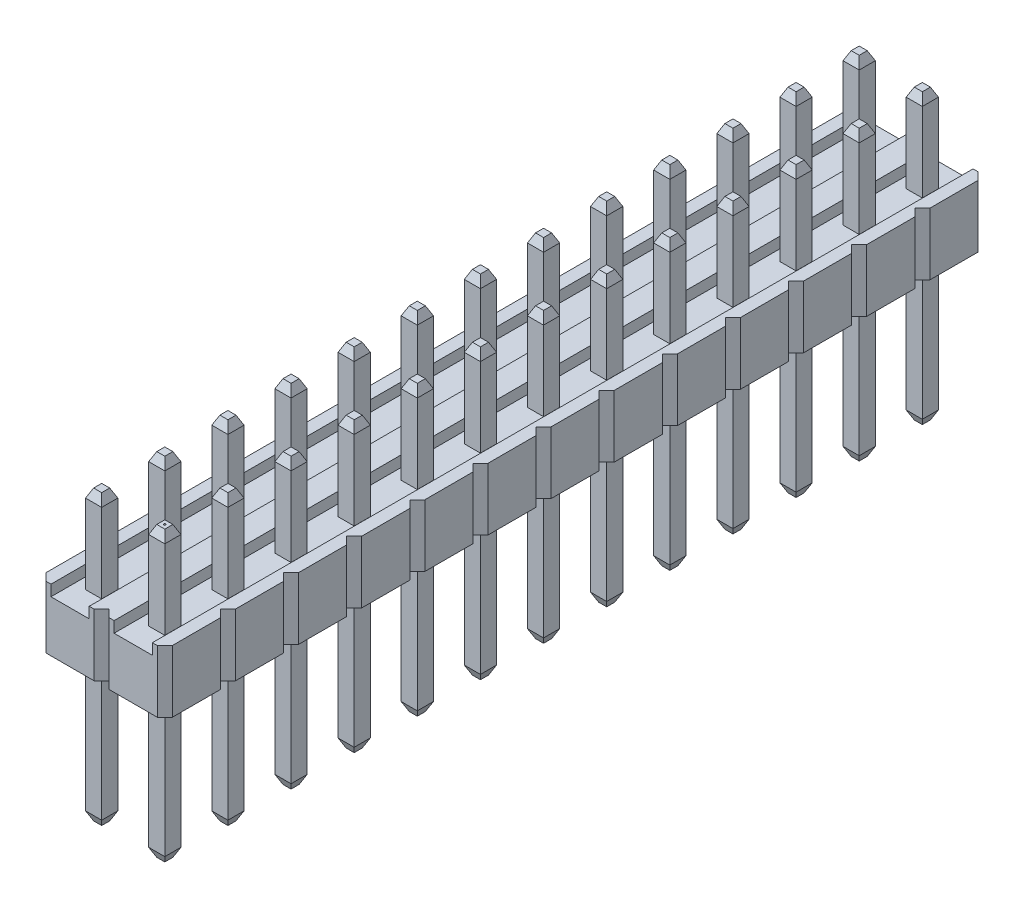
from build123d import *

# Parameters (mm, degrees)
EXTRUDE1_DEPTH                     = 2.5
SKETCH2_W                          = 1.54
SKETCH2_H                          = 0.508742985
CUT_EXTRUDE1_DEPTH                 = 12.5
SKETCH3_W                          = 0.65
SKETCH3_H                          = 0.65
EXTRUDE2_DEPTH                     = 3.54
CHAMFER1_SIZE                      = 0.35
CHAMFER1_SIZE2                     = 0.16320768
CHAMFER1_PART_2_SIZE               = 0.35
CHAMFER1_PART_2_SIZE2              = 0.16320768
CHAMFER1_PART_3_SIZE               = 0.35
CHAMFER1_PART_3_SIZE2              = 0.16320768
CHAMFER1_PART_4_SIZE               = 0.35
CHAMFER1_PART_4_SIZE2              = 0.16320768
SKETCH4_W                          = 0.65
SKETCH4_H                          = 0.65
EXTRUDE3_DEPTH                     = 6
CHAMFER2_SIZE                      = 0.35
CHAMFER2_SIZE2                     = 0.16320768
CHAMFER2_PART_2_SIZE               = 0.35
CHAMFER2_PART_2_SIZE2              = 0.16320768
CHAMFER2_PART_3_SIZE               = 0.35
CHAMFER2_PART_3_SIZE2              = 0.16320768
CHAMFER2_PART_4_SIZE               = 0.35
CHAMFER2_PART_4_SIZE2              = 0.16320768
LPATTERN3_COUNT                    = 13
LPATTERN3_PITCH                    = 2.54
LPATTERN3_COUNT_DIR2               = 2
LPATTERN3_PITCH_DIR2               = 2.54
LPATTERN4_COUNT                    = 13
LPATTERN4_PITCH                    = 2.54
LPATTERN4_COUNT_DIR2               = 2
LPATTERN4_PITCH_DIR2               = 2.54
CHAMFER1_OF_LPATTERN4_SIZE2        = 0.16320768
CHAMFER1_OF_LPATTERN4_SIZE         = 0.35
CHAMFER1_PART_2_OF_LPATTERN4_SIZE2 = 0.16320768
CHAMFER1_PART_2_OF_LPATTERN4_SIZE  = 0.35
CHAMFER1_PART_3_OF_LPATTERN4_SIZE2 = 0.16320768
CHAMFER1_PART_3_OF_LPATTERN4_SIZE  = 0.35
CHAMFER1_PART_4_OF_LPATTERN4_SIZE2 = 0.16320768
CHAMFER1_PART_4_OF_LPATTERN4_SIZE  = 0.35
CHAMFER2_OF_LPATTERN4_SIZE2        = 0.16320768
CHAMFER2_OF_LPATTERN4_SIZE         = 0.35
CHAMFER2_PART_2_OF_LPATTERN4_SIZE2 = 0.16320768
CHAMFER2_PART_2_OF_LPATTERN4_SIZE  = 0.35
CHAMFER2_PART_3_OF_LPATTERN4_SIZE2 = 0.16320768
CHAMFER2_PART_3_OF_LPATTERN4_SIZE  = 0.35
CHAMFER2_PART_4_OF_LPATTERN4_SIZE2 = 0.16320768
CHAMFER2_PART_4_OF_LPATTERN4_SIZE  = 0.35
ESBO_O1_R                          = 0.039608668
CORTE_EXTRUS_O1_DEPTH              = 0.1


with BuildPart() as part:
    # Sketch1 → Extrude1 (new body)
    with BuildSketch(Plane(origin=(0, 0, 0), x_dir=(1, 0, 0), z_dir=(0, 1, 0))):
        Polygon((-0.97, 1.27), (0.97, 1.27), (1.27, 0.97), (1.27, -0.97), (0.97, -1.27), (-0.97, -1.27), (-1.27, -0.97), (-1.27, 0.97), align=None)
    extrude1 = extrude(amount=EXTRUDE1_DEPTH)

    # Sketch2 → Cut-Extrude1 (cut)
    with BuildSketch(Plane.XY.offset(1.27)):
        with Locations((0, 2.314371493)):
            Rectangle(SKETCH2_W, SKETCH2_H)
    cut_extrude1 = extrude(amount=-CUT_EXTRUDE1_DEPTH, mode=Mode.SUBTRACT)

    # Sketch3 → Extrude2 (add)
    with BuildSketch(Plane(origin=(0, 2.06, 0), x_dir=(-1, 0, 0), z_dir=(0, 1, 0))):
        Rectangle(SKETCH3_W, SKETCH3_H)
    extrude2 = extrude(amount=EXTRUDE2_DEPTH)

    # Chamfer1
    chamfer1_edges = [part.edges().sort_by_distance(p)[0] for p in [
        (-0.325, 5.6, 0),
    ]]
    chamfer1_side = [part.faces().sort_by_distance(p)[0] for p in [
        (-0.325, 3.83, 0),
    ]]
    chamfer(chamfer1_edges, length=CHAMFER1_SIZE, length2=CHAMFER1_SIZE2, reference=chamfer1_side[0])

    # Chamfer1 part 2
    chamfer1_part_2_edges = [part.edges().sort_by_distance(p)[0] for p in [
        (0, 5.6, 0.325),
    ]]
    chamfer1_part_2_side = [part.faces().sort_by_distance(p)[0] for p in [
        (0, 3.83, 0.325),
    ]]
    chamfer(chamfer1_part_2_edges, length=CHAMFER1_PART_2_SIZE, length2=CHAMFER1_PART_2_SIZE2, reference=chamfer1_part_2_side[0])

    # Chamfer1 part 3
    chamfer1_part_3_edges = [part.edges().sort_by_distance(p)[0] for p in [
        (0.325, 5.6, 0),
    ]]
    chamfer1_part_3_side = [part.faces().sort_by_distance(p)[0] for p in [
        (0.325, 3.83, 0),
    ]]
    chamfer(chamfer1_part_3_edges, length=CHAMFER1_PART_3_SIZE, length2=CHAMFER1_PART_3_SIZE2, reference=chamfer1_part_3_side[0])

    # Chamfer1 part 4
    chamfer1_part_4_edges = [part.edges().sort_by_distance(p)[0] for p in [
        (0, 5.6, -0.325),
    ]]
    chamfer1_part_4_side = [part.faces().sort_by_distance(p)[0] for p in [
        (0, 3.83, -0.325),
    ]]
    chamfer(chamfer1_part_4_edges, length=CHAMFER1_PART_4_SIZE, length2=CHAMFER1_PART_4_SIZE2, reference=chamfer1_part_4_side[0])

    # Sketch4 → Extrude3 (add)
    with BuildSketch(Plane.XZ):
        Rectangle(SKETCH4_W, SKETCH4_H)
    extrude3 = extrude(amount=EXTRUDE3_DEPTH)

    # Chamfer2
    chamfer2_edges = [part.edges().sort_by_distance(p)[0] for p in [
        (-0.325, -6, 0),
    ]]
    chamfer2_side = [part.faces().sort_by_distance(p)[0] for p in [
        (-0.325, -3, 0),
    ]]
    chamfer(chamfer2_edges, length=CHAMFER2_SIZE, length2=CHAMFER2_SIZE2, reference=chamfer2_side[0])

    # Chamfer2 part 2
    chamfer2_part_2_edges = [part.edges().sort_by_distance(p)[0] for p in [
        (0, -6, -0.325),
    ]]
    chamfer2_part_2_side = [part.faces().sort_by_distance(p)[0] for p in [
        (0, -3, -0.325),
    ]]
    chamfer(chamfer2_part_2_edges, length=CHAMFER2_PART_2_SIZE, length2=CHAMFER2_PART_2_SIZE2, reference=chamfer2_part_2_side[0])

    # Chamfer2 part 3
    chamfer2_part_3_edges = [part.edges().sort_by_distance(p)[0] for p in [
        (0.325, -6, 0),
    ]]
    chamfer2_part_3_side = [part.faces().sort_by_distance(p)[0] for p in [
        (0.325, -3, 0),
    ]]
    chamfer(chamfer2_part_3_edges, length=CHAMFER2_PART_3_SIZE, length2=CHAMFER2_PART_3_SIZE2, reference=chamfer2_part_3_side[0])

    # Chamfer2 part 4
    chamfer2_part_4_edges = [part.edges().sort_by_distance(p)[0] for p in [
        (0, -6, 0.325),
    ]]
    chamfer2_part_4_side = [part.faces().sort_by_distance(p)[0] for p in [
        (0, -3, 0.325),
    ]]
    chamfer(chamfer2_part_4_edges, length=CHAMFER2_PART_4_SIZE, length2=CHAMFER2_PART_4_SIZE2, reference=chamfer2_part_4_side[0])

    # LPattern3: Extrude1, Cut-Extrude1 13 × 2
    with Locations(*[(-j * LPATTERN3_PITCH_DIR2, 0, -i * LPATTERN3_PITCH) for i in range(LPATTERN3_COUNT) for j in range(LPATTERN3_COUNT_DIR2) if (i, j) != (0, 0)]):
        add(extrude1)
        add(cut_extrude1, mode=Mode.SUBTRACT)

    # LPattern4: Extrude2, Extrude3 13 × 2
    with Locations(*[(-j * LPATTERN4_PITCH_DIR2, 0, -i * LPATTERN4_PITCH) for i in range(LPATTERN4_COUNT) for j in range(LPATTERN4_COUNT_DIR2) if (i, j) != (0, 0)]):
        add(extrude2)
        add(extrude3)

    # Chamfer1 of LPattern4
    chamfer1_of_lpattern4_edges = [part.edges().sort_by_distance(p)[0] for p in [
        (-2.865, 5.6, 0),
        (-0.325, 5.6, -2.54),
        (-2.865, 5.6, -2.54),
        (-0.325, 5.6, -5.08),
        (-2.865, 5.6, -5.08),
        (-0.325, 5.6, -7.62),
        (-2.865, 5.6, -7.62),
        (-0.325, 5.6, -10.16),
        (-2.865, 5.6, -10.16),
        (-0.325, 5.6, -12.7),
        (-2.865, 5.6, -12.7),
        (-0.325, 5.6, -15.24),
        (-2.865, 5.6, -15.24),
        (-0.325, 5.6, -17.78),
        (-2.865, 5.6, -17.78),
        (-0.325, 5.6, -20.32),
        (-2.865, 5.6, -20.32),
        (-0.325, 5.6, -22.86),
        (-2.865, 5.6, -22.86),
        (-0.325, 5.6, -25.4),
        (-2.865, 5.6, -25.4),
        (-0.325, 5.6, -27.94),
        (-2.865, 5.6, -27.94),
        (-0.325, 5.6, -30.48),
        (-2.865, 5.6, -30.48),
    ]]
    chamfer(chamfer1_of_lpattern4_edges, length=CHAMFER1_OF_LPATTERN4_SIZE, length2=CHAMFER1_OF_LPATTERN4_SIZE2)

    # Chamfer1 part 2 of LPattern4
    chamfer1_part_2_of_lpattern4_edges = [part.edges().sort_by_distance(p)[0] for p in [
        (-2.54, 5.6, 0.325),
        (0, 5.6, -2.215),
        (-2.54, 5.6, -2.215),
        (0, 5.6, -4.755),
        (-2.54, 5.6, -4.755),
        (0, 5.6, -7.295),
        (-2.54, 5.6, -7.295),
        (0, 5.6, -9.835),
        (-2.54, 5.6, -9.835),
        (0, 5.6, -12.375),
        (-2.54, 5.6, -12.375),
        (0, 5.6, -14.915),
        (-2.54, 5.6, -14.915),
        (0, 5.6, -17.455),
        (-2.54, 5.6, -17.455),
        (0, 5.6, -19.995),
        (-2.54, 5.6, -19.995),
        (0, 5.6, -22.535),
        (-2.54, 5.6, -22.535),
        (0, 5.6, -25.075),
        (-2.54, 5.6, -25.075),
        (0, 5.6, -27.615),
        (-2.54, 5.6, -27.615),
        (0, 5.6, -30.155),
        (-2.54, 5.6, -30.155),
    ]]
    chamfer(chamfer1_part_2_of_lpattern4_edges, length=CHAMFER1_PART_2_OF_LPATTERN4_SIZE, length2=CHAMFER1_PART_2_OF_LPATTERN4_SIZE2)

    # Chamfer1 part 3 of LPattern4
    chamfer1_part_3_of_lpattern4_edges = [part.edges().sort_by_distance(p)[0] for p in [
        (-2.215, 5.6, 0),
        (0.325, 5.6, -2.54),
        (-2.215, 5.6, -2.54),
        (0.325, 5.6, -5.08),
        (-2.215, 5.6, -5.08),
        (0.325, 5.6, -7.62),
        (-2.215, 5.6, -7.62),
        (0.325, 5.6, -10.16),
        (-2.215, 5.6, -10.16),
        (0.325, 5.6, -12.7),
        (-2.215, 5.6, -12.7),
        (0.325, 5.6, -15.24),
        (-2.215, 5.6, -15.24),
        (0.325, 5.6, -17.78),
        (-2.215, 5.6, -17.78),
        (0.325, 5.6, -20.32),
        (-2.215, 5.6, -20.32),
        (0.325, 5.6, -22.86),
        (-2.215, 5.6, -22.86),
        (0.325, 5.6, -25.4),
        (-2.215, 5.6, -25.4),
        (0.325, 5.6, -27.94),
        (-2.215, 5.6, -27.94),
        (0.325, 5.6, -30.48),
        (-2.215, 5.6, -30.48),
    ]]
    chamfer(chamfer1_part_3_of_lpattern4_edges, length=CHAMFER1_PART_3_OF_LPATTERN4_SIZE, length2=CHAMFER1_PART_3_OF_LPATTERN4_SIZE2)

    # Chamfer1 part 4 of LPattern4
    chamfer1_part_4_of_lpattern4_edges = [part.edges().sort_by_distance(p)[0] for p in [
        (-2.54, 5.6, -0.325),
        (0, 5.6, -2.865),
        (-2.54, 5.6, -2.865),
        (0, 5.6, -5.405),
        (-2.54, 5.6, -5.405),
        (0, 5.6, -7.945),
        (-2.54, 5.6, -7.945),
        (0, 5.6, -10.485),
        (-2.54, 5.6, -10.485),
        (0, 5.6, -13.025),
        (-2.54, 5.6, -13.025),
        (0, 5.6, -15.565),
        (-2.54, 5.6, -15.565),
        (0, 5.6, -18.105),
        (-2.54, 5.6, -18.105),
        (0, 5.6, -20.645),
        (-2.54, 5.6, -20.645),
        (0, 5.6, -23.185),
        (-2.54, 5.6, -23.185),
        (0, 5.6, -25.725),
        (-2.54, 5.6, -25.725),
        (0, 5.6, -28.265),
        (-2.54, 5.6, -28.265),
        (0, 5.6, -30.805),
        (-2.54, 5.6, -30.805),
    ]]
    chamfer(chamfer1_part_4_of_lpattern4_edges, length=CHAMFER1_PART_4_OF_LPATTERN4_SIZE, length2=CHAMFER1_PART_4_OF_LPATTERN4_SIZE2)

    # Chamfer2 of LPattern4
    chamfer2_of_lpattern4_edges = [part.edges().sort_by_distance(p)[0] for p in [
        (-2.865, -6, 0),
        (-0.325, -6, -2.54),
        (-2.865, -6, -2.54),
        (-0.325, -6, -5.08),
        (-2.865, -6, -5.08),
        (-0.325, -6, -7.62),
        (-2.865, -6, -7.62),
        (-0.325, -6, -10.16),
        (-2.865, -6, -10.16),
        (-0.325, -6, -12.7),
        (-2.865, -6, -12.7),
        (-0.325, -6, -15.24),
        (-2.865, -6, -15.24),
        (-0.325, -6, -17.78),
        (-2.865, -6, -17.78),
        (-0.325, -6, -20.32),
        (-2.865, -6, -20.32),
        (-0.325, -6, -22.86),
        (-2.865, -6, -22.86),
        (-0.325, -6, -25.4),
        (-2.865, -6, -25.4),
        (-0.325, -6, -27.94),
        (-2.865, -6, -27.94),
        (-0.325, -6, -30.48),
        (-2.865, -6, -30.48),
    ]]
    chamfer(chamfer2_of_lpattern4_edges, length=CHAMFER2_OF_LPATTERN4_SIZE, length2=CHAMFER2_OF_LPATTERN4_SIZE2)

    # Chamfer2 part 2 of LPattern4
    chamfer2_part_2_of_lpattern4_edges = [part.edges().sort_by_distance(p)[0] for p in [
        (-2.54, -6, -0.325),
        (0, -6, -2.865),
        (-2.54, -6, -2.865),
        (0, -6, -5.405),
        (-2.54, -6, -5.405),
        (0, -6, -7.945),
        (-2.54, -6, -7.945),
        (0, -6, -10.485),
        (-2.54, -6, -10.485),
        (0, -6, -13.025),
        (-2.54, -6, -13.025),
        (0, -6, -15.565),
        (-2.54, -6, -15.565),
        (0, -6, -18.105),
        (-2.54, -6, -18.105),
        (0, -6, -20.645),
        (-2.54, -6, -20.645),
        (0, -6, -23.185),
        (-2.54, -6, -23.185),
        (0, -6, -25.725),
        (-2.54, -6, -25.725),
        (0, -6, -28.265),
        (-2.54, -6, -28.265),
        (0, -6, -30.805),
        (-2.54, -6, -30.805),
    ]]
    chamfer(chamfer2_part_2_of_lpattern4_edges, length=CHAMFER2_PART_2_OF_LPATTERN4_SIZE, length2=CHAMFER2_PART_2_OF_LPATTERN4_SIZE2)

    # Chamfer2 part 3 of LPattern4
    chamfer2_part_3_of_lpattern4_edges = [part.edges().sort_by_distance(p)[0] for p in [
        (-2.215, -6, 0),
        (0.325, -6, -2.54),
        (-2.215, -6, -2.54),
        (0.325, -6, -5.08),
        (-2.215, -6, -5.08),
        (0.325, -6, -7.62),
        (-2.215, -6, -7.62),
        (0.325, -6, -10.16),
        (-2.215, -6, -10.16),
        (0.325, -6, -12.7),
        (-2.215, -6, -12.7),
        (0.325, -6, -15.24),
        (-2.215, -6, -15.24),
        (0.325, -6, -17.78),
        (-2.215, -6, -17.78),
        (0.325, -6, -20.32),
        (-2.215, -6, -20.32),
        (0.325, -6, -22.86),
        (-2.215, -6, -22.86),
        (0.325, -6, -25.4),
        (-2.215, -6, -25.4),
        (0.325, -6, -27.94),
        (-2.215, -6, -27.94),
        (0.325, -6, -30.48),
        (-2.215, -6, -30.48),
    ]]
    chamfer(chamfer2_part_3_of_lpattern4_edges, length=CHAMFER2_PART_3_OF_LPATTERN4_SIZE, length2=CHAMFER2_PART_3_OF_LPATTERN4_SIZE2)

    # Chamfer2 part 4 of LPattern4
    chamfer2_part_4_of_lpattern4_edges = [part.edges().sort_by_distance(p)[0] for p in [
        (-2.54, -6, 0.325),
        (0, -6, -2.215),
        (-2.54, -6, -2.215),
        (0, -6, -4.755),
        (-2.54, -6, -4.755),
        (0, -6, -7.295),
        (-2.54, -6, -7.295),
        (0, -6, -9.835),
        (-2.54, -6, -9.835),
        (0, -6, -12.375),
        (-2.54, -6, -12.375),
        (0, -6, -14.915),
        (-2.54, -6, -14.915),
        (0, -6, -17.455),
        (-2.54, -6, -17.455),
        (0, -6, -19.995),
        (-2.54, -6, -19.995),
        (0, -6, -22.535),
        (-2.54, -6, -22.535),
        (0, -6, -25.075),
        (-2.54, -6, -25.075),
        (0, -6, -27.615),
        (-2.54, -6, -27.615),
        (0, -6, -30.155),
        (-2.54, -6, -30.155),
    ]]
    chamfer(chamfer2_part_4_of_lpattern4_edges, length=CHAMFER2_PART_4_OF_LPATTERN4_SIZE, length2=CHAMFER2_PART_4_OF_LPATTERN4_SIZE2)

    # Esboço1 → Corte-extrusão1 (cut)
    with BuildSketch(Plane(origin=(0, 5.6, 0), x_dir=(1, 0, 0), z_dir=(0, 1, 0))):
        Circle(ESBO_O1_R)
    extrude(amount=-CORTE_EXTRUS_O1_DEPTH, mode=Mode.SUBTRACT)


solid = part.part
